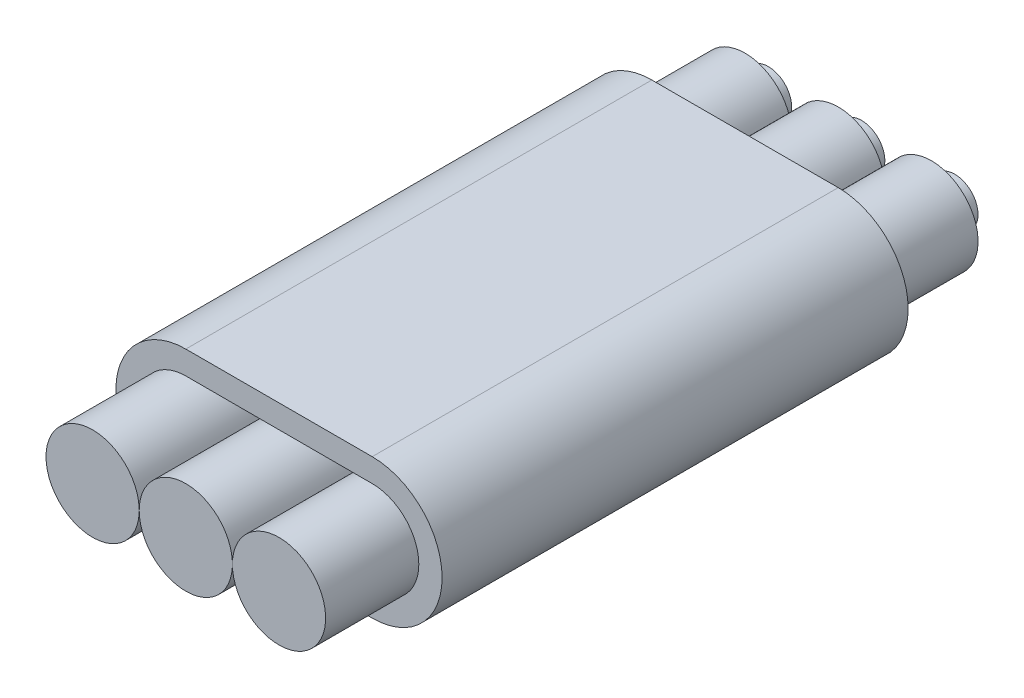
from build123d import *

# Parameters (mm, degrees)
EXTRUDE_THIN1_DEPTH      = 10
SKETCH2_R                = 1
SKETCH2_R_2              = 0.5
EXTRUDE_THIN2_DEPTH      = 2
EXTRUDE_THIN2_DEPTH_BACK = 12
SKETCH3_R                = 0.5
BOSS_EXTRUDE1_DEPTH      = 0.5
BOSS_EXTRUDE1_DEPTH_BACK = 14


with BuildPart() as part:
    # Sketch1 → Extrude-Thin1 (new body)
    with BuildSketch(Plane.XY):
        with BuildLine():
            Line((2, -1.5), (-2, -1.5))
            ThreePointArc((-2, -1.5), (-3.5, 0), (-2, 1.5))
            Line((-2, 1.5), (2, 1.5))
            ThreePointArc((2, 1.5), (3.5, 0), (2, -1.5))
        make_face()
        with BuildLine():
            Line((2, -1), (-2, -1))
            ThreePointArc((-2, -1), (-3, 0), (-2, 1))
            Line((-2, 1), (2, 1))
            ThreePointArc((2, 1), (3, 0), (2, -1))
        make_face(mode=Mode.SUBTRACT)
    extrude(amount=EXTRUDE_THIN1_DEPTH)

    # Sketch2 → Extrude-Thin2 (add, two sides)
    with BuildSketch(Plane(origin=(0, 0, 0), x_dir=(-1, 0, 0), z_dir=(0, 0, -1))) as extrude_thin2_sk:
        Circle(SKETCH2_R)
        Circle(SKETCH2_R_2, mode=Mode.SUBTRACT)
        with Locations((2, 0)):
            Circle(SKETCH2_R)
        with Locations((2, 0)):
            Circle(SKETCH2_R_2, mode=Mode.SUBTRACT)
        with Locations((-2, 0)):
            Circle(SKETCH2_R)
        with Locations((-2, 0)):
            Circle(SKETCH2_R_2, mode=Mode.SUBTRACT)
    extrude(amount=EXTRUDE_THIN2_DEPTH)
    extrude(extrude_thin2_sk.sketch, amount=-EXTRUDE_THIN2_DEPTH_BACK)

    # Sketch3 → Boss-Extrude1 (add, two sides)
    with BuildSketch(Plane(origin=(0, 0, -2), x_dir=(-1, 0, 0), z_dir=(0, 0, -1))) as boss_extrude1_sk:
        with Locations((-2, 0)):
            Circle(SKETCH3_R)
        Circle(SKETCH3_R)
        with Locations((2, 0)):
            Circle(SKETCH3_R)
    extrude(amount=BOSS_EXTRUDE1_DEPTH)
    extrude(boss_extrude1_sk.sketch, amount=-BOSS_EXTRUDE1_DEPTH_BACK)


solid = part.part
